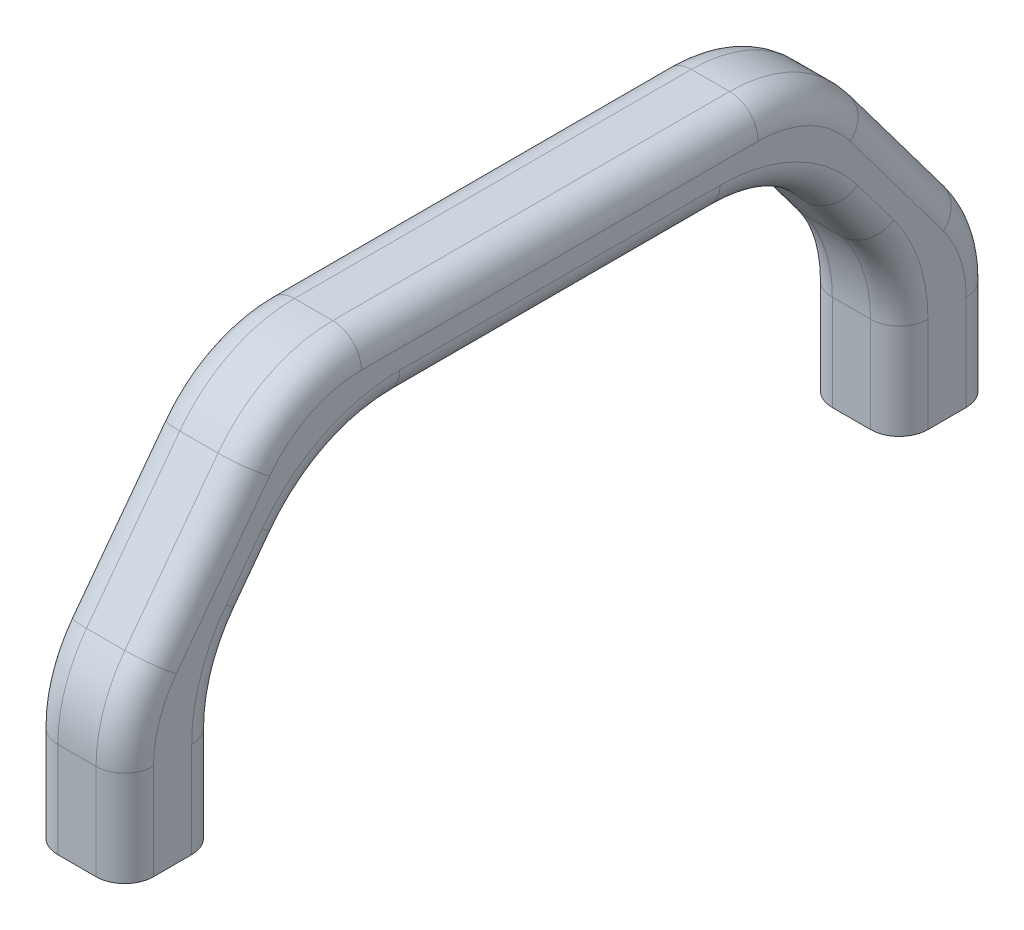
from build123d import *

# Parameters (mm, degrees)
SKETCH1_W             = 10
SKETCH1_H             = 10
SKETCH1_R             = 1.6
BOSS_EXTRUDE1_DEPTH   = 15
BOSS_EXTRUDE1_2_DEPTH = 15
BOSS_EXTRUDE2_DEPTH   = 10
FILLET1_R             = 15
FILLET2_R             = 3


with BuildPart() as part:
    # Sketch1 → Boss-Extrude1 (new body)
    with BuildSketch(Plane(origin=(0, 0, 0), x_dir=(1, 0, 0), z_dir=(0, 1, 0))):
        with Locations((-1.586813187, 40.5)):
            Rectangle(SKETCH1_W, SKETCH1_H)
        with Locations((-1.586813187, 40.5)):
            Circle(SKETCH1_R, mode=Mode.SUBTRACT)
    extrude(amount=BOSS_EXTRUDE1_DEPTH)



with BuildPart() as body_2:
    # Sketch1 → Boss-Extrude1 2 (new body)
    with BuildSketch(Plane(origin=(0, 0, 0), x_dir=(1, 0, 0), z_dir=(0, 1, 0))):
        with Locations((-1.586813187, -40.5)):
            Rectangle(SKETCH1_W, SKETCH1_H)
        with Locations((-1.586813187, -40.5)):
            Circle(SKETCH1_R, mode=Mode.SUBTRACT)
    extrude(amount=BOSS_EXTRUDE1_2_DEPTH)


with BuildPart() as part_1:
    add(part.part)

    add(body_2.part)  # Boss-Extrude2 merges body 2
    # Sketch4 → Boss-Extrude2 (add)
    with BuildSketch(Plane(origin=(3.413186813, 0, 0), x_dir=(0, 0, -1), z_dir=(1, 0, 0))):
        Polygon((-35.5, 15), (-24.25, 30), (24.25, 30), (35.5, 15), (45.5, 15), (28.25, 38), (-28.25, 38), (-45.5, 15), align=None)
    extrude(amount=-BOSS_EXTRUDE2_DEPTH)

    # Fillet1
    fillet1_edges = [part_1.edges().sort_by_distance(p)[0] for p in [
        (-1.586813187, 15, -35.5),
        (-1.586813187, 15, 35.5),
        (-1.586813187, 15, 45.5),
        (-1.586813187, 38, 28.25),
        (-1.586813187, 38, -28.25),
        (-1.586813187, 30, -24.25),
        (-1.586813187, 30, 24.25),
        (-1.586813187, 15, -45.5),
    ]]
    fillet(fillet1_edges, radius=FILLET1_R)

    # Fillet2
    fillet2_edges = [part_1.edges().sort_by_distance(p)[0] for p in [
        (-6.586813187, 5, 35.5),
        (3.413186813, 5, 35.5),
        (3.413186813, 21.5, 30.625),
        (-6.586813187, 21.5, 30.625),
        (3.413186813, 25.5, 37.625),
        (-6.586813187, 25.5, 37.625),
        (3.413186813, 5, -45.5),
        (3.413186813, 25.5, -37.625),
        (3.413186813, 38, 0),
        (3.413186813, 5, 45.5),
        (3.413186813, 30, 0),
        (3.413186813, 21.5, -30.625),
        (3.413186813, 5, -35.5),
        (3.413186813, 36.416407865, -27.458203932),
        (3.413186813, 14.74341649, -44.730249471),
        (3.413186813, 36.416407865, 27.458203932),
        (3.413186813, 14.74341649, 44.730249471),
        (-6.586813187, 5, 45.5),
        (-6.586813187, 5, -35.5),
        (-6.586813187, 21.5, -30.625),
        (-6.586813187, 30, 0),
        (-6.586813187, 38, 0),
        (-6.586813187, 25.5, -37.625),
        (-6.586813187, 5, -45.5),
        (-6.586813187, 36.416407865, -27.458203932),
        (-6.586813187, 14.74341649, -44.730249471),
        (-6.586813187, 36.416407865, 27.458203932),
        (-6.586813187, 14.74341649, 44.730249471),
        (3.413186813, 14.74341649, 34.730249471),
        (-6.586813187, 14.74341649, 34.730249471),
        (3.413186813, 28.416407865, 23.458203932),
        (-6.586813187, 28.416407865, 23.458203932),
        (3.413186813, 28.416407865, -23.458203932),
        (-6.586813187, 28.416407865, -23.458203932),
        (3.413186813, 14.74341649, -34.730249471),
        (-6.586813187, 14.74341649, -34.730249471),
    ]]
    fillet(fillet2_edges, radius=FILLET2_R)


solid = part_1.part
